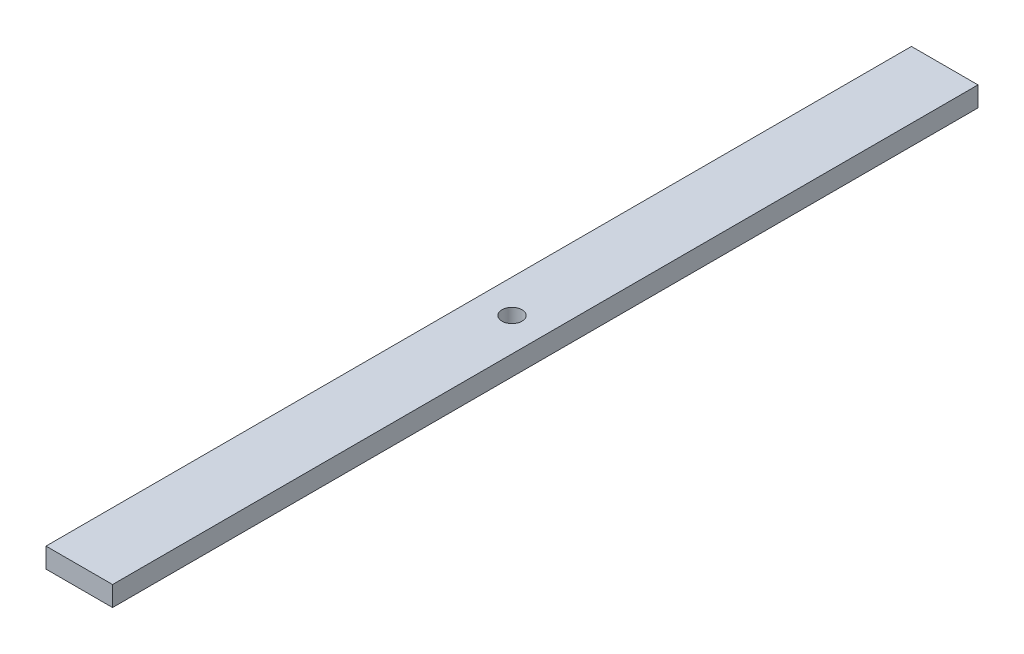
from build123d import *

# Parameters (mm, degrees)
SKETCH1_W           = 10
SKETCH1_H           = 130
SKETCH1_R           = 1.5
BOSS_EXTRUDE1_DEPTH = 3


with BuildPart() as part:
    # Sketch1 → Boss-Extrude1 (new body)
    with BuildSketch(Plane(origin=(0, 0, 0), x_dir=(1, 0, 0), z_dir=(0, 1, 0))):
        Rectangle(SKETCH1_W, SKETCH1_H)
        Circle(SKETCH1_R, mode=Mode.SUBTRACT)
    extrude(amount=BOSS_EXTRUDE1_DEPTH)


solid = part.part
